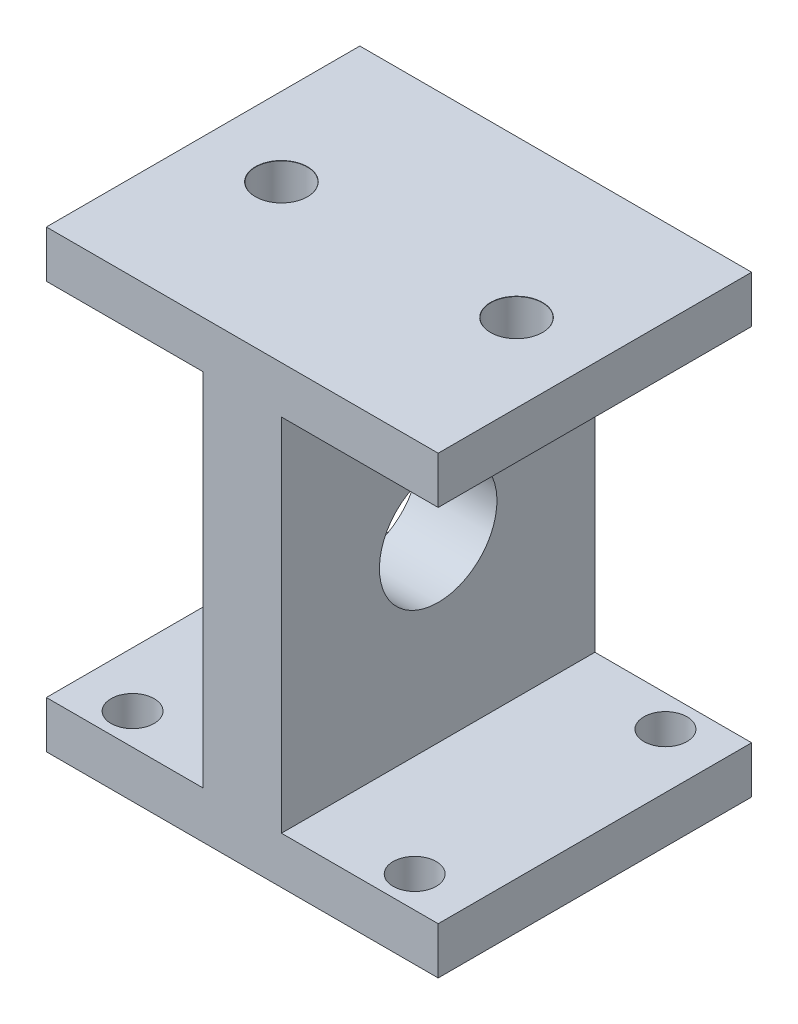
from build123d import *

# Parameters (mm, degrees)
SKETCH_1_W                   = 50
SKETCH_1_H                   = 58
EXTRUDE_1_DEPTH              = 40
SKETCH_2_W                   = 32.792818714
SKETCH_2_H                   = 46
CUT_EXTRUDE_1_DEPTH          = 60
SKETCH_3_R                   = 7.5
CUT_EXTRUDE_2_DEPTH          = 35
HOLE_WIZARD_M5_1_D           = 5.5
HOLE_WIZARD_M5_1_DEPTH       = 17
HOLE_WIZARD_M5_1_CSINK_D     = 5.55
HOLE_WIZARD_M5_1_CSINK_ANGLE = 90
HOLE_WIZARD_M5_1_TIP         = 1.652366702
HOLE_WIZARD_M6_1_D           = 6.6
HOLE_WIZARD_M6_1_DEPTH       = 17
HOLE_WIZARD_M6_1_CSINK_D     = 6.65
HOLE_WIZARD_M6_1_CSINK_ANGLE = 90
HOLE_WIZARD_M6_1_TIP         = 1.982840043


with BuildPart() as part:
    # 草图1 → 凸台-拉伸1 (new body)
    with BuildSketch(Plane.XY):
        Rectangle(SKETCH_1_W, SKETCH_1_H)
    extrude(amount=EXTRUDE_1_DEPTH)

    # 草图2 → 切除-拉伸1 (cut)
    with BuildSketch(Plane.XY.offset(40)):
        with Locations((-21.396409357, 0)):
            Rectangle(SKETCH_2_W, SKETCH_2_H)
        with Locations((21.396409357, 0)):
            Rectangle(SKETCH_2_W, SKETCH_2_H)
    extrude(amount=-CUT_EXTRUDE_1_DEPTH, mode=Mode.SUBTRACT)

    # 草图3 → 切除-拉伸2 (cut)
    with BuildSketch(Plane.ZY.offset(5)):
        with Locations((20, 0)):
            Circle(SKETCH_3_R)
    extrude(amount=-CUT_EXTRUDE_2_DEPTH, mode=Mode.SUBTRACT)

    # M5 间隙槽口1
    with Locations(Plane(origin=(0, -29, 0), x_dir=(-1, 0, 0), z_dir=(0, -1, 0))):
        with Locations((-18, -4), (18, -4), (18, -36), (-18, -36)):
            CounterSinkHole(HOLE_WIZARD_M5_1_D / 2, HOLE_WIZARD_M5_1_CSINK_D / 2, depth=HOLE_WIZARD_M5_1_DEPTH, counter_sink_angle=HOLE_WIZARD_M5_1_CSINK_ANGLE)
            with Locations((0, 0, -(HOLE_WIZARD_M5_1_DEPTH + HOLE_WIZARD_M5_1_TIP / 2))):  # 118° drill point
                Cone(0, HOLE_WIZARD_M5_1_D / 2, HOLE_WIZARD_M5_1_TIP, mode=Mode.SUBTRACT)

    # M6 间隙槽口1
    with Locations(Plane(origin=(0, 29, 0), x_dir=(1, 0, 0), z_dir=(0, 1, 0))):
        with Locations((-15, -20), (15, -20)):
            CounterSinkHole(HOLE_WIZARD_M6_1_D / 2, HOLE_WIZARD_M6_1_CSINK_D / 2, depth=HOLE_WIZARD_M6_1_DEPTH, counter_sink_angle=HOLE_WIZARD_M6_1_CSINK_ANGLE)
            with Locations((0, 0, -(HOLE_WIZARD_M6_1_DEPTH + HOLE_WIZARD_M6_1_TIP / 2))):  # 118° drill point
                Cone(0, HOLE_WIZARD_M6_1_D / 2, HOLE_WIZARD_M6_1_TIP, mode=Mode.SUBTRACT)


solid = part.part
